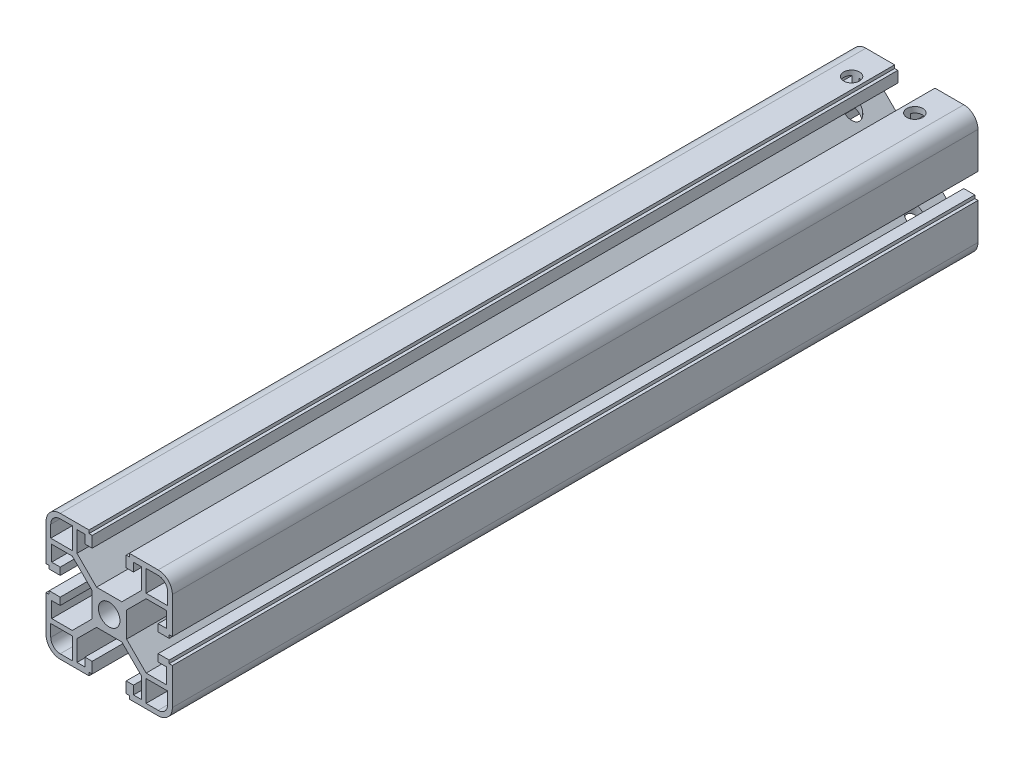
from build123d import *

# Parameters (mm, degrees)
BOSS_EXTRUDE1_DEPTH     = 255
MIRROR3_COPY_1_DEPTH    = 255
MIRROR3_COPY_2_DEPTH    = 255
SKETCH2_R               = 2.5
CUT_EXTRUDE1_DEPTH      = 15.5
CUT_EXTRUDE1_DEPTH_BACK = 26.5


with BuildPart() as part:
    # Sketch1 → Boss-Extrude1 (new body)
    with BuildSketch(Plane.XY):
        with BuildLine():
            Line((3.4, 0), (5.5, 0))
            Line((5.5, 0), (5.5, 4))
            Line((5.5, 4), (11.69, 10.19))
            Line((11.69, 10.19), (18.2, 10.19))
            Line((18.2, 10.19), (18.2, 5.265595036))
            Line((18.2, 5.265595036), (15.5, 5.265595036))
            Line((15.5, 5.265595036), (15.5, 2.965595036))
            Line((15.5, 2.965595036), (19, 2.965595036))
            Line((19, 2.965595036), (19, 3.965595036))
            Line((19, 3.965595036), (20, 3.965595036))
            Line((20, 3.965595036), (20, 15.5))
            ThreePointArc((20, 15.5), (18.681980515, 18.681980515), (15.5, 20))
            Line((15.5, 20), (6.385304712, 20))
            Line((6.385304712, 20), (6.385304712, 19))
            Line((6.385304712, 19), (5.385304712, 19))
            Line((5.385304712, 19), (5.385304712, 15.5))
            Line((5.385304712, 15.5), (7.685304712, 15.5))
            Line((7.685304712, 15.5), (7.685304712, 18.2))
            Line((7.685304712, 18.2), (10.19, 18.2))
            Line((10.19, 18.2), (10.19, 11.69))
            Line((10.19, 11.69), (4, 5.5))
            Line((4, 5.5), (0, 5.5))
            Line((0, 5.5), (0, 3.4))
            ThreePointArc((0, 3.4), (2.404163056, 2.404163056), (3.4, 0))
        make_face()
        with BuildLine():
            Line((18.5, 11.69), (18.5, 15.5))
            ThreePointArc((18.5, 15.5), (17.621320344, 17.621320344), (15.5, 18.5))
            Line((15.5, 18.5), (11.69, 18.5))
            Line((11.69, 18.5), (11.69, 11.69))
            Line((11.69, 11.69), (18.5, 11.69))
        make_face(mode=Mode.SUBTRACT)
    boss_extrude1 = extrude(amount=BOSS_EXTRUDE1_DEPTH)

    # Mirror1: Boss-Extrude1 across plane
    add(boss_extrude1.mirror(Plane.ZX))

    # Mirror2: Boss-Extrude1 across plane
    add(boss_extrude1.mirror(Plane(origin=(0, 0, 0), x_dir=(0, 0, 1), z_dir=(1, 0, 0))))

    # Mirror3 copy 1 sketch → Mirror3 copy 1 (add)
    with BuildSketch(Plane(origin=(0, 0, 0), x_dir=(-1, 0, 0), z_dir=(0, 0, 1))):
        with BuildLine():
            Line((3.4, 0), (5.5, 0))
            Line((5.5, 0), (5.5, 4))
            Line((5.5, 4), (11.69, 10.19))
            Line((11.69, 10.19), (18.2, 10.19))
            Line((18.2, 10.19), (18.2, 5.265595036))
            Line((18.2, 5.265595036), (15.5, 5.265595036))
            Line((15.5, 5.265595036), (15.5, 2.965595036))
            Line((15.5, 2.965595036), (19, 2.965595036))
            Line((19, 2.965595036), (19, 3.965595036))
            Line((19, 3.965595036), (20, 3.965595036))
            Line((20, 3.965595036), (20, 15.5))
            ThreePointArc((20, 15.5), (18.681980515, 18.681980515), (15.5, 20))
            Line((15.5, 20), (6.385304712, 20))
            Line((6.385304712, 20), (6.385304712, 19))
            Line((6.385304712, 19), (5.385304712, 19))
            Line((5.385304712, 19), (5.385304712, 15.5))
            Line((5.385304712, 15.5), (7.685304712, 15.5))
            Line((7.685304712, 15.5), (7.685304712, 18.2))
            Line((7.685304712, 18.2), (10.19, 18.2))
            Line((10.19, 18.2), (10.19, 11.69))
            Line((10.19, 11.69), (4, 5.5))
            Line((4, 5.5), (0, 5.5))
            Line((0, 5.5), (0, 3.4))
            ThreePointArc((0, 3.4), (2.404163056, 2.404163056), (3.4, 0))
        make_face()
        with BuildLine():
            Line((18.5, 11.69), (18.5, 15.5))
            ThreePointArc((18.5, 15.5), (17.621320344, 17.621320344), (15.5, 18.5))
            Line((15.5, 18.5), (11.69, 18.5))
            Line((11.69, 18.5), (11.69, 11.69))
            Line((11.69, 11.69), (18.5, 11.69))
        make_face(mode=Mode.SUBTRACT)
    extrude(amount=MIRROR3_COPY_1_DEPTH)

    # Mirror3 copy 2 sketch → Mirror3 copy 2 (add)
    with BuildSketch(Plane.XY):
        with BuildLine():
            Line((3.4, 0), (5.5, 0))
            Line((5.5, 0), (5.5, -4))
            Line((5.5, -4), (11.69, -10.19))
            Line((11.69, -10.19), (18.2, -10.19))
            Line((18.2, -10.19), (18.2, -5.265595036))
            Line((18.2, -5.265595036), (15.5, -5.265595036))
            Line((15.5, -5.265595036), (15.5, -2.965595036))
            Line((15.5, -2.965595036), (19, -2.965595036))
            Line((19, -2.965595036), (19, -3.965595036))
            Line((19, -3.965595036), (20, -3.965595036))
            Line((20, -3.965595036), (20, -15.5))
            ThreePointArc((20, -15.5), (18.681980515, -18.681980515), (15.5, -20))
            Line((15.5, -20), (6.385304712, -20))
            Line((6.385304712, -20), (6.385304712, -19))
            Line((6.385304712, -19), (5.385304712, -19))
            Line((5.385304712, -19), (5.385304712, -15.5))
            Line((5.385304712, -15.5), (7.685304712, -15.5))
            Line((7.685304712, -15.5), (7.685304712, -18.2))
            Line((7.685304712, -18.2), (10.19, -18.2))
            Line((10.19, -18.2), (10.19, -11.69))
            Line((10.19, -11.69), (4, -5.5))
            Line((4, -5.5), (0, -5.5))
            Line((0, -5.5), (0, -3.4))
            ThreePointArc((0, -3.4), (2.404163056, -2.404163056), (3.4, 0))
        make_face()
        with BuildLine():
            Line((18.5, -11.69), (18.5, -15.5))
            ThreePointArc((18.5, -15.5), (17.621320344, -17.621320344), (15.5, -18.5))
            Line((15.5, -18.5), (11.69, -18.5))
            Line((11.69, -18.5), (11.69, -11.69))
            Line((11.69, -11.69), (18.5, -11.69))
        make_face(mode=Mode.SUBTRACT)
    extrude(amount=MIRROR3_COPY_2_DEPTH)

    # Sketch2 → Cut-Extrude1 (cut, two sides)
    with BuildSketch(Plane(origin=(0, 5.5, 0), x_dir=(1, 0, 0), z_dir=(0, 1, 0))) as cut_extrude1_sk:
        with Locations((-10, -10)):
            Circle(SKETCH2_R)
        with Locations((10, -10)):
            Circle(SKETCH2_R)
    extrude(amount=CUT_EXTRUDE1_DEPTH, mode=Mode.SUBTRACT)
    extrude(cut_extrude1_sk.sketch, amount=-CUT_EXTRUDE1_DEPTH_BACK, mode=Mode.SUBTRACT)


solid = part.part
